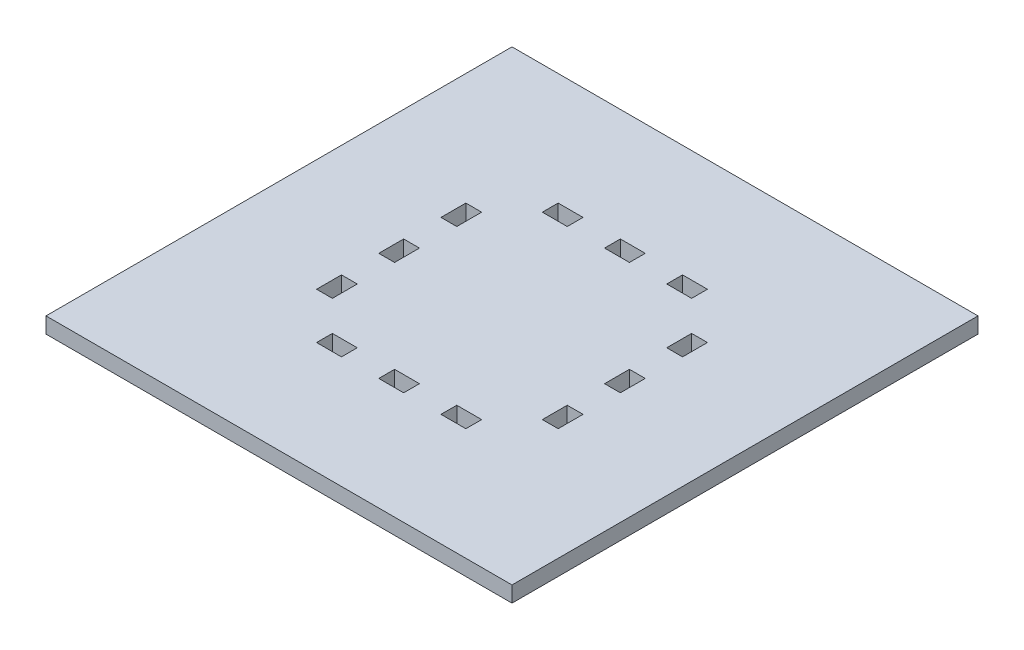
from build123d import *

# Parameters (mm, degrees)
SKETCH1_W           = 93.65
SKETCH1_H           = 93.65
BOSS_EXTRUDE1_DEPTH = 3.175
SKETCH2_W           = 5
SKETCH2_H           = 3.175
SKETCH2_W_2         = 3.175
SKETCH2_H_2         = 5
CUT_EXTRUDE1_DEPTH  = 3.175


with BuildPart() as part:
    # Sketch1 → Boss-Extrude1 (new body)
    with BuildSketch(Plane(origin=(0, 0, 0), x_dir=(1, 0, 0), z_dir=(0, 1, 0))):
        Rectangle(SKETCH1_W, SKETCH1_H)
    extrude(amount=BOSS_EXTRUDE1_DEPTH)

    # Sketch2 → Cut-Extrude1 (cut)
    with BuildSketch(Plane(origin=(0, 3.175, 0), x_dir=(1, 0, 0), z_dir=(0, 1, 0))):
        with Locations((-12.5, -22.6875)):
            Rectangle(SKETCH2_W, SKETCH2_H)
        with Locations((0, -22.6875)):
            Rectangle(SKETCH2_W, SKETCH2_H)
        with Locations((12.5, -22.6875)):
            Rectangle(SKETCH2_W, SKETCH2_H)
        with Locations((22.6875, -12.5)):
            Rectangle(SKETCH2_W_2, SKETCH2_H_2)
        with Locations((22.6875, 0)):
            Rectangle(SKETCH2_W_2, SKETCH2_H_2)
        with Locations((22.6875, 12.5)):
            Rectangle(SKETCH2_W_2, SKETCH2_H_2)
        with Locations((12.5, 22.6875)):
            Rectangle(SKETCH2_W, SKETCH2_H)
        with Locations((0, 22.6875)):
            Rectangle(SKETCH2_W, SKETCH2_H)
        with Locations((-12.5, 22.6875)):
            Rectangle(SKETCH2_W, SKETCH2_H)
        with Locations((-22.6875, 12.5)):
            Rectangle(SKETCH2_W_2, SKETCH2_H_2)
        with Locations((-22.6875, 0)):
            Rectangle(SKETCH2_W_2, SKETCH2_H_2)
        with Locations((-22.6875, -12.5)):
            Rectangle(SKETCH2_W_2, SKETCH2_H_2)
    extrude(amount=-CUT_EXTRUDE1_DEPTH, mode=Mode.SUBTRACT)


solid = part.part
